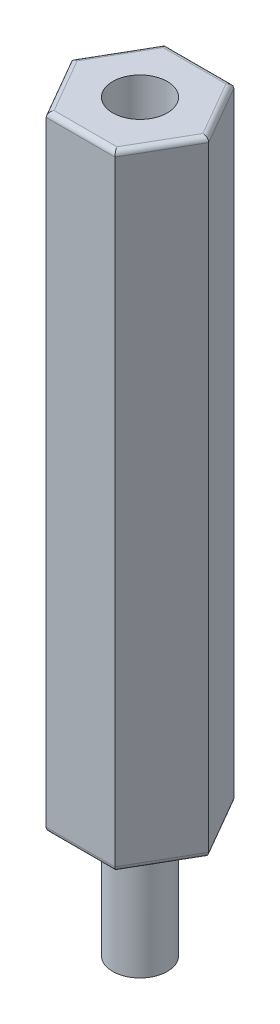
from build123d import *

# Parameters (mm, degrees)
RESSALTO_EXTRUS_O1_DEPTH = 25
FILETE1_R                = 0.2
ESBO_O2_R                = 1.0922
RESSALTO_EXTRUS_O2_DEPTH = 4.76
ESBO_O3_R                = 1.0922
CORTE_EXTRUS_O1_DEPTH    = 4.76


with BuildPart() as part:
    # Esboço1 → Ressalto-extrusão1 (new body)
    with BuildSketch(Plane(origin=(0, 0, 0), x_dir=(1, 0, 0), z_dir=(0, 1, 0))):
        Polygon((2.748187281, 0), (1.374093641, 2.38), (-1.374093641, 2.38), (-2.748187281, 0), (-1.374093641, -2.38), (1.374093641, -2.38), align=None)
    extrude(amount=RESSALTO_EXTRUS_O1_DEPTH)

    # Filete1
    filete1_edges = [part.edges().sort_by_distance(p)[0] for p in [
        (0, 25, -2.38),
        (-2.061140461, 25, -1.19),
        (-2.061140461, 25, 1.19),
        (0, 25, 2.38),
        (2.061140461, 25, 1.19),
        (0, 0, 2.38),
        (-2.061140461, 0, 1.19),
        (-2.061140461, 0, -1.19),
        (2.061140461, 25, -1.19),
        (0, 0, -2.38),
        (2.061140461, 0, -1.19),
        (2.061140461, 0, 1.19),
    ]]
    fillet(filete1_edges, radius=FILETE1_R)

    # Esboço2 → Ressalto-extrusão2 (add)
    with BuildSketch(Plane.XZ):
        Circle(ESBO_O2_R)
    extrude(amount=RESSALTO_EXTRUS_O2_DEPTH)

    # Esboço3 → Corte-extrusão1 (cut)
    with BuildSketch(Plane(origin=(0, 25, 0), x_dir=(1, 0, 0), z_dir=(0, 1, 0))):
        Circle(ESBO_O3_R)
    extrude(amount=-CORTE_EXTRUS_O1_DEPTH, mode=Mode.SUBTRACT)


solid = part.part
